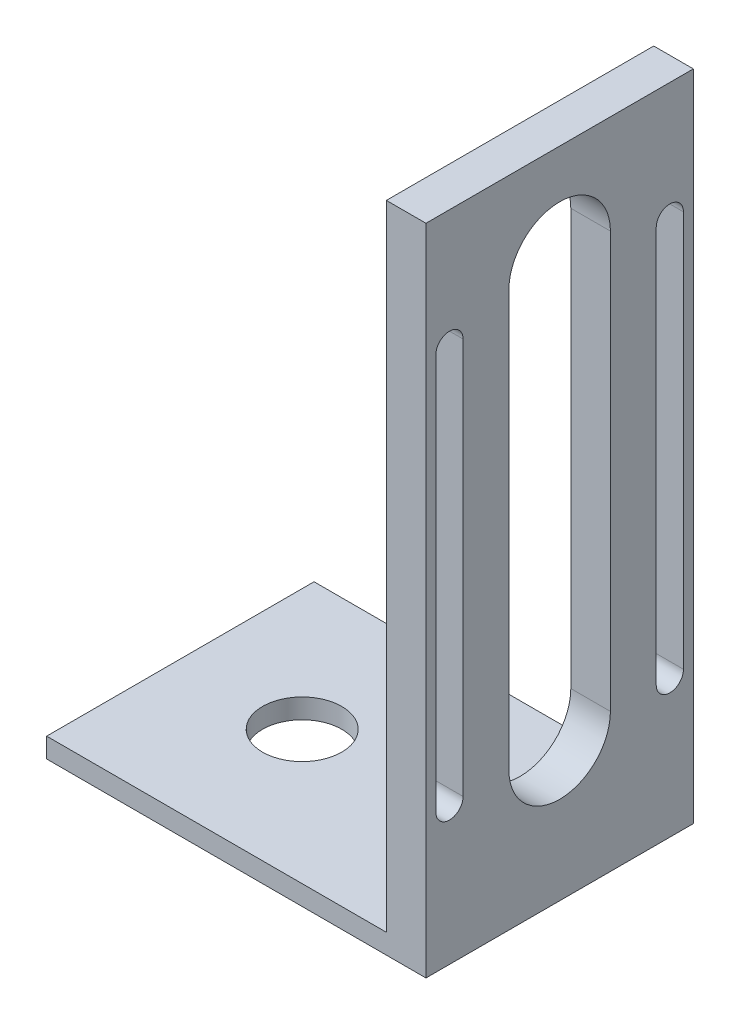
from build123d import *

# Parameters (mm, degrees)
SKETCH1_W           = 38.3
SKETCH1_H           = 27
SKETCH1_R           = 4
BOSS_EXTRUDE1_DEPTH = 2
SKETCH2_W           = 4
SKETCH2_H           = 27
BOSS_EXTRUDE2_DEPTH = 64
CUT_EXTRUDE1_REACH  = 6


with BuildPart() as part:
    # Sketch1 → Boss-Extrude1 (new body)
    with BuildSketch(Plane(origin=(0, 0, 0), x_dir=(1, 0, 0), z_dir=(0, 1, 0))):
        Rectangle(SKETCH1_W, SKETCH1_H)
        with Locations((-6.85, 0)):
            Circle(SKETCH1_R, mode=Mode.SUBTRACT)
    extrude(amount=BOSS_EXTRUDE1_DEPTH)

    # Sketch2 → Boss-Extrude2 (add)
    with BuildSketch(Plane(origin=(0, 2, 0), x_dir=(1, 0, 0), z_dir=(0, 1, 0))):
        with Locations((17.15, 0)):
            Rectangle(SKETCH2_W, SKETCH2_H)
    extrude(amount=BOSS_EXTRUDE2_DEPTH)

    # Sketch3 → Cut-Extrude1 (cut, up to next)
    with BuildSketch(Plane.ZY.offset(-15.15), mode=Mode.PRIVATE) as cut_extrude1_sk1:
        with BuildLine():
            Line((-12.5, 14), (-12.5, 54))
            ThreePointArc((-12.5, 54), (-11.125, 55.375), (-9.75, 54))
            Line((-9.75, 54), (-9.75, 14))
            ThreePointArc((-9.75, 14), (-11.125, 12.625), (-12.5, 14))
        make_face()
    cut_extrude1_tool1 = extrude(cut_extrude1_sk1.sketch, amount=-CUT_EXTRUDE1_REACH, mode=Mode.PRIVATE) & part.part
    add(cut_extrude1_tool1.solids().sort_by_distance((15.15, 34, -11.125))[0], mode=Mode.SUBTRACT)
    # Sketch3 → Cut-Extrude1 (cut, up to next)
    with BuildSketch(Plane.ZY.offset(-15.15), mode=Mode.PRIVATE) as cut_extrude1_sk2:
        with BuildLine():
            Line((12.5, 14), (12.5, 54))
            ThreePointArc((12.5, 54), (11.125, 55.375), (9.75, 54))
            Line((9.75, 54), (9.75, 14))
            ThreePointArc((9.75, 14), (11.125, 12.625), (12.5, 14))
        make_face()
    cut_extrude1_tool2 = extrude(cut_extrude1_sk2.sketch, amount=-CUT_EXTRUDE1_REACH, mode=Mode.PRIVATE) & part.part
    add(cut_extrude1_tool2.solids().sort_by_distance((15.15, 34, 11.125))[0], mode=Mode.SUBTRACT)
    # Sketch3 → Cut-Extrude1 (cut, up to next)
    with BuildSketch(Plane.ZY.offset(-15.15), mode=Mode.PRIVATE) as cut_extrude1_sk3:
        with BuildLine():
            Line((-5.125, 14), (-5.125, 56))
            ThreePointArc((-5.125, 56), (0, 61.125), (5.125, 56))
            Line((5.125, 56), (5.125, 14))
            ThreePointArc((5.125, 14), (0, 8.875), (-5.125, 14))
        make_face()
    cut_extrude1_tool3 = extrude(cut_extrude1_sk3.sketch, amount=-CUT_EXTRUDE1_REACH, mode=Mode.PRIVATE) & part.part
    add(cut_extrude1_tool3.solids().sort_by_distance((15.15, 35, 0))[0], mode=Mode.SUBTRACT)


solid = part.part
